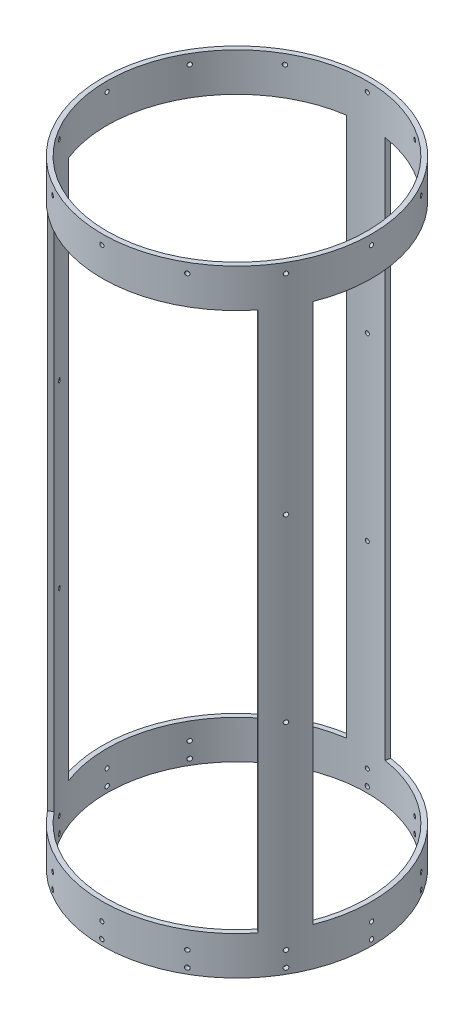
from build123d import *

# Parameters (mm, degrees)
SKETCH1_R               = 88.9
SKETCH1_R_2             = 85.725
BOSS_EXTRUDE1_DEPTH     = 203.2
CUT_EXTRUDE5_START      = -25.4
CUT_EXTRUDE5_DEPTH      = 355.6
CIRPATTERN5_COUNT       = 3
CUT_EXTRUDE2_REACH      = 240.949
CUT_EXTRUDE2_END_RADIUS = 88.9
SKETCH3_R               = 1.4351
SKETCH3_R_2             = 1.35255
CIRPATTERN2_COUNT       = 12
SKETCH4_R               = 1.35255
CUT_EXTRUDE3_DEPTH      = 15.24
CIRPATTERN3_COUNT       = 12
CUT_EXTRUDE4_REACH      = 286.264
SKETCH5_R               = 1.35255
CIRPATTERN4_COUNT       = 3


with BuildPart() as part:
    # Sketch1 → Boss-Extrude1 (new, symmetric)
    with BuildSketch(Plane(origin=(0, 0, 0), x_dir=(1, 0, 0), z_dir=(0, 1, 0))):
        with Locations(Location((0, 0, 0), (0, 0, 270))):
            Circle(SKETCH1_R)
        with Locations(Location((0, 0, 0), (0, 0, 270))):
            Circle(SKETCH1_R_2, mode=Mode.SUBTRACT)
    extrude(amount=BOSS_EXTRUDE1_DEPTH, both=True)

    # Sketch6 → Cut-Extrude5 (cut)
    with BuildSketch(Plane(origin=(0, -203.2, 0), x_dir=(-1, 0, 0), z_dir=(0, -1, 0)).offset(CUT_EXTRUDE5_START)):
        with BuildLine():
            Line((82.79008563, -32.388450433), (79.833296857, -31.23172006))
            ThreePointArc((79.833296857, -31.23172006), (74.185462692, 42.956870815), (12.653594621, 84.785978606))
            Line((12.653594621, 84.785978606), (13.122246274, 87.926200036))
            ThreePointArc((13.122246274, 87.926200036), (76.933072421, 44.54786603), (82.79008563, -32.388450433))
        make_face()
    cut_extrude5 = extrude(amount=-CUT_EXTRUDE5_DEPTH, mode=Mode.SUBTRACT)

    # CirPattern5: Cut-Extrude5 ×3 about axis
    cirpattern5_axis = Axis((0, 0, 0), (0, 1, 0))
    for i in range(1, CIRPATTERN5_COUNT):
        add(cut_extrude5.rotate(cirpattern5_axis, i * 360 / CIRPATTERN5_COUNT), mode=Mode.SUBTRACT)

    # Cut-Extrude2: up to this cylinder (the profile starts inside it)
    cut_extrude2_end = Plane(origin=(0, -194.31, 0), z_dir=(0, -1, 0)) * Cylinder(CUT_EXTRUDE2_END_RADIUS, 670.858, mode=Mode.PRIVATE)
    # Sketch3 → Cut-Extrude2 (cut, up to the surface)
    with BuildSketch(Plane(origin=(0, 0, 0), x_dir=(-1, 0, 0), z_dir=(0, 0, -1)), mode=Mode.PRIVATE) as cut_extrude2_sk1:
        with Locations(Location((-0.169185452, -199.39, 0), (0, 0, 180))):
            Circle(SKETCH3_R)
    cut_extrude2_tool1 = extrude(cut_extrude2_sk1.sketch, amount=CUT_EXTRUDE2_REACH, mode=Mode.PRIVATE) & cut_extrude2_end
    # Sketch3 → Cut-Extrude2 (cut, up to the surface)
    with BuildSketch(Plane(origin=(0, 0, 0), x_dir=(-1, 0, 0), z_dir=(0, 0, -1)), mode=Mode.PRIVATE) as cut_extrude2_sk2:
        with Locations(Location((-0.169185452, -189.23, 0), (0, 0, 180))):
            Circle(SKETCH3_R_2)
    cut_extrude2_tool2 = extrude(cut_extrude2_sk2.sketch, amount=CUT_EXTRUDE2_REACH, mode=Mode.PRIVATE) & cut_extrude2_end
    cut_extrude2 = cut_extrude2_tool1.solids().sort_by_distance((0.169185, -199.39, 0))[0] + cut_extrude2_tool2.solids().sort_by_distance((0.169185, -189.23, 0))[0]
    add(cut_extrude2, mode=Mode.SUBTRACT)

    # CirPattern2: Cut-Extrude2 ×12 about axis
    cirpattern2_axis = Axis((0, 203.2, 0), (0, -1, 0))
    for i in range(1, CIRPATTERN2_COUNT):
        add(cut_extrude2.rotate(cirpattern2_axis, i * 360 / CIRPATTERN2_COUNT), mode=Mode.SUBTRACT)

    # Sketch4 → Cut-Extrude3 (cut)
    with BuildSketch(Plane(origin=(0, 0, -88.9), x_dir=(-1, 0, 0), z_dir=(0, 0, -1))):
        with Locations(Location((-0.169185452, 196.85, 0), (0, 0, 82.814261444))):
            Circle(SKETCH4_R)
    cut_extrude3 = extrude(amount=-CUT_EXTRUDE3_DEPTH, mode=Mode.SUBTRACT)

    # CirPattern3: Cut-Extrude3 ×12 about axis
    cirpattern3_axis = Axis((0, 203.2, 0), (0, 1, 0))
    for i in range(1, CIRPATTERN3_COUNT):
        add(cut_extrude3.rotate(cirpattern3_axis, i * 360 / CIRPATTERN3_COUNT), mode=Mode.SUBTRACT)

    # Sketch5 → Cut-Extrude4 (cut, up to next)
    with BuildSketch(Plane.XY.offset(88.9), mode=Mode.PRIVATE) as cut_extrude4_sk1:
        with Locations((0.169185452, 59.266666667)):
            Circle(SKETCH5_R)
    cut_extrude4_tool1 = extrude(cut_extrude4_sk1.sketch, amount=-CUT_EXTRUDE4_REACH, mode=Mode.PRIVATE) & part.part
    # Sketch5 → Cut-Extrude4 (cut, up to next)
    with BuildSketch(Plane.XY.offset(88.9), mode=Mode.PRIVATE) as cut_extrude4_sk2:
        with Locations((0.169185452, -59.266666667)):
            Circle(SKETCH5_R)
    cut_extrude4_tool2 = extrude(cut_extrude4_sk2.sketch, amount=-CUT_EXTRUDE4_REACH, mode=Mode.PRIVATE) & part.part
    cut_extrude4_1 = cut_extrude4_tool1.solids().sort_by_distance((0.169185, 59.266667, 88.9))[0]
    add(cut_extrude4_1, mode=Mode.SUBTRACT)
    cut_extrude4_2 = cut_extrude4_tool2.solids().sort_by_distance((0.169185, -59.266667, 88.9))[0]
    add(cut_extrude4_2, mode=Mode.SUBTRACT)
    cut_extrude4 = cut_extrude4_1 + cut_extrude4_2  # Cut-Extrude4 as one shape, for the pattern or mirror that repeats it

    # CirPattern4: Cut-Extrude4 ×3 about axis
    cirpattern4_axis = Axis((0, 203.2, 0), (0, -1, 0))
    for i in range(1, CIRPATTERN4_COUNT):
        add(cut_extrude4.rotate(cirpattern4_axis, i * 360 / CIRPATTERN4_COUNT), mode=Mode.SUBTRACT)


solid = part.part
